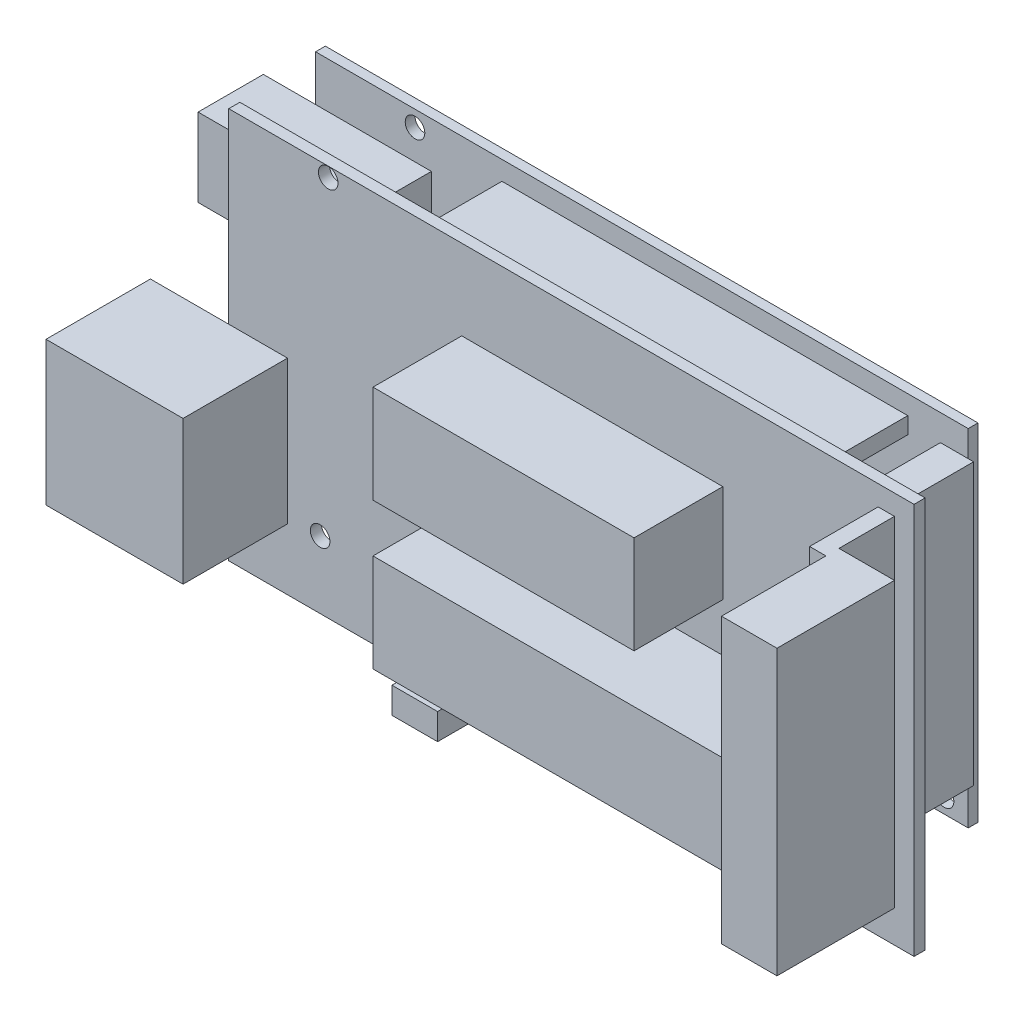
from build123d import *

# Parameters (mm, degrees)
ESBO_O1_W                 = 105
ESBO_O1_H                 = 60
RESSALTO_EXTRUS_O1_DEPTH  = 1.7
ESBO_O2_W                 = 60
ESBO_O2_H                 = 15
ESBO_O2_W_2               = 40
RESSALTO_EXTRUS_O2_DEPTH  = 13.6
RESSALTO_EXTRUS_O6_START  = 11.6
ESBO_O3_W                 = 100
ESBO_O3_H                 = 53
RESSALTO_EXTRUS_O6_DEPTH  = 1.5
ESBO_O4_W                 = 62.184169383
ESBO_O4_H                 = 2.54
ESBO_O4_W_2               = 5.08
ESBO_O4_H_2               = 42.957805244
ESBO_O4_W_3               = 56.07185462
RESSALTO_EXTRUS_O8_DEPTH  = 11.6
ESBO_O6_W                 = 21
ESBO_O6_H                 = 22
RESSALTO_EXTRUS_O9_DEPTH  = 16
ESBO_O7_W                 = 25.746964405
ESBO_O7_H                 = 12
RESSALTO_EXTRUS_O10_DEPTH = 10
ESBO_O8_R                 = 1.5
CORTE_EXTRUS_O1_DEPTH     = 31.8
RESSALTO_EXTRUS_O11_DEPTH = 56.905179
CORTE_EXTRUS_O2_DEPTH     = 11
RESSALTO_EXTRUS_O12_START = 1
ESBO_O12_W                = 7
ESBO_O12_H                = 7
RESSALTO_EXTRUS_O12_DEPTH = 4


with BuildPart() as part:
    # Esboço1 → Ressalto-extrusão1 (new body)
    with BuildSketch(Plane.XY):
        Rectangle(ESBO_O1_W, ESBO_O1_H)
    extrude(amount=RESSALTO_EXTRUS_O1_DEPTH)

    # Esboço2 → Ressalto-extrusão2 (add)
    with BuildSketch(Plane.XY.offset(1.7)):
        with Locations((13.2, -12.2)):
            Rectangle(ESBO_O2_W, ESBO_O2_H)
        with Locations((3.2, 10.2)):
            Rectangle(ESBO_O2_W_2, ESBO_O2_H)
    extrude(amount=RESSALTO_EXTRUS_O2_DEPTH)



with BuildPart() as body_2:
    # Esboço3 → Ressalto-extrusão6 (new body)
    with BuildSketch(Plane(origin=(0, 0, 0), x_dir=(-1, 0, 0), z_dir=(0, 0, -1)).offset(RESSALTO_EXTRUS_O6_START)):
        with Locations((2.5, 4.4)):
            Rectangle(ESBO_O3_W, ESBO_O3_H)
    extrude(amount=RESSALTO_EXTRUS_O6_DEPTH)


with BuildPart() as part_1:
    add(part.part)

    add(body_2.part)  # Ressalto-extrusão8 merges body 2
    # Esboço4 → Ressalto-extrusão8 (add)
    with BuildSketch(Plane.XY.offset(-11.6)):
        with Locations((7.150543675, 26.719832293)):
            Rectangle(ESBO_O4_W, ESBO_O4_H)
        with Locations((45.784919315, 5.42627648)):
            Rectangle(ESBO_O4_W_2, ESBO_O4_H_2)
        with Locations((10.206701056, -18.689881399)):
            Rectangle(ESBO_O4_W_3, ESBO_O4_H)
    extrude(amount=RESSALTO_EXTRUS_O8_DEPTH)

    # Esboço6 → Ressalto-extrusão9 (add)
    with BuildSketch(Plane.XY.offset(1.7)):
        with Locations((-54, -9.6)):
            Rectangle(ESBO_O6_W, ESBO_O6_H)
    extrude(amount=RESSALTO_EXTRUS_O9_DEPTH)

    # Esboço7 → Ressalto-extrusão10 (add)
    with BuildSketch(Plane.XY.offset(-11.6)):
        with Locations((-47.626517798, 17.9)):
            Rectangle(ESBO_O7_W, ESBO_O7_H)
    extrude(amount=RESSALTO_EXTRUS_O10_DEPTH)

    # Esboço8 → Corte-extrusão1 (cut, through all)
    with BuildSketch(Plane(origin=(0, 0, -13.1), x_dir=(-1, 0, 0), z_dir=(0, 0, -1))):
        with Locations((37.26, 28.47)):
            Circle(ESBO_O8_R)
        with Locations((38.5, -19.7)):
            Circle(ESBO_O8_R)
        with Locations((-43.8, -19.7)):
            Circle(ESBO_O8_R)
    extrude(amount=-CORTE_EXTRUS_O1_DEPTH, mode=Mode.SUBTRACT)

    # Esboço9 → Ressalto-extrusão11 (add)
    with BuildSketch(Plane.XZ.offset(30)):
        Polygon((49.5, 1.7), (49.5, 10.2), (58, 10.2), (58, 28.2), (49.5, 28.2), (49.5, 12.2), (47, 12.2), (47, 1.7), align=None)
    extrude(amount=-RESSALTO_EXTRUS_O11_DEPTH)

    # Esboço10 → Corte-extrusão2 (cut)
    with BuildSketch(Plane(origin=(58, 0, 0), x_dir=(0, 0, -1), z_dir=(1, 0, 0))):
        Polygon((-10.2, -16.57372352), (-28.2, -16.57372352), (-28.2, -30), (-1.7, -30), (-1.7, -16.57372352), align=None)
    extrude(amount=-CORTE_EXTRUS_O2_DEPTH, mode=Mode.SUBTRACT)

    # Esboço12 → Ressalto-extrusão12 (add)
    with BuildSketch(Plane.XZ.offset(30).offset(RESSALTO_EXTRUS_O12_START)):
        with Locations((-17, 5.2)):
            Rectangle(ESBO_O12_W, ESBO_O12_H)
    extrude(amount=-RESSALTO_EXTRUS_O12_DEPTH)


solid = part_1.part
